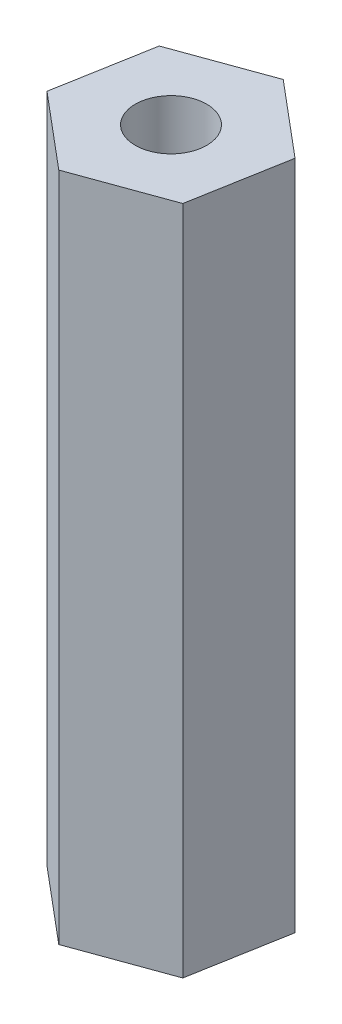
from build123d import *

# Parameters (mm, degrees)
BOSS_EXTRUDE1_DEPTH = 25.4
SKETCH2_R           = 1.35255
CUT_EXTRUDE1_DEPTH  = 26.4


with BuildPart() as part:
    # Sketch1 → Boss-Extrude1 (new body)
    with BuildSketch(Plane(origin=(0, 0, 0), x_dir=(1, 0, 0), z_dir=(0, 1, 0))):
        Polygon((-2.80595074, 2.359549486), (-3.446405166, -1.25024988), (-0.640454426, -3.609799366), (2.80595074, -2.359549486), (3.446405166, 1.25024988), (0.640454426, 3.609799366), align=None)
    extrude(amount=BOSS_EXTRUDE1_DEPTH)

    # Sketch2 → Cut-Extrude1 (cut, through all)
    with BuildSketch(Plane(origin=(0, 25.4, 0), x_dir=(1, 0, 0), z_dir=(0, 1, 0))):
        Circle(SKETCH2_R)
    extrude(amount=-CUT_EXTRUDE1_DEPTH, mode=Mode.SUBTRACT)


solid = part.part
